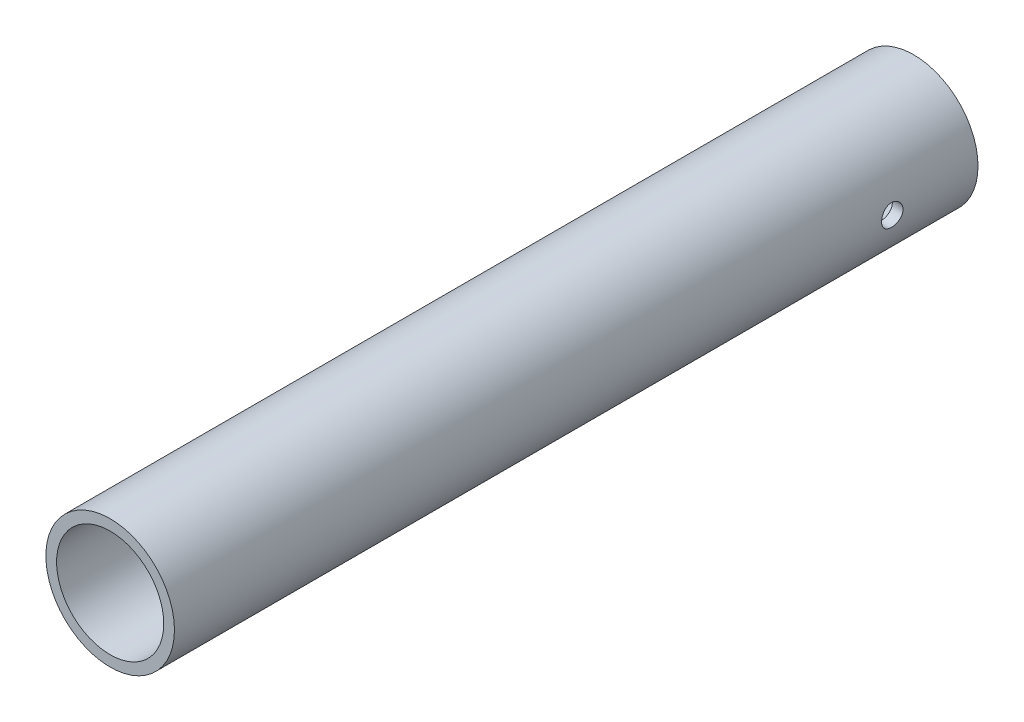
from build123d import *

# Parameters (mm, degrees)
SKETCH1_R                  = 6
SKETCH1_R_2                = 5
BOSS_EXTRUDE1_DEPTH        = 75
IZIM1_R                    = 1
KES_EKSTR_ZYON1_DEPTH      = 7
KES_EKSTR_ZYON1_DEPTH_BACK = 7


with BuildPart() as part:
    # Sketch1 → Boss-Extrude1 (new body)
    with BuildSketch(Plane.XY):
        Circle(SKETCH1_R)
        Circle(SKETCH1_R_2, mode=Mode.SUBTRACT)
    extrude(amount=BOSS_EXTRUDE1_DEPTH)

    # Çizim1 → Kes-Ekstrüzyon1 (cut, two sides)
    with BuildSketch(Plane(origin=(0, 0, 0), x_dir=(0, 0, -1), z_dir=(1, 0, 0))) as kes_ekstr_zyon1_sk:
        with Locations((-8, 0)):
            Circle(IZIM1_R)
    extrude(amount=KES_EKSTR_ZYON1_DEPTH, mode=Mode.SUBTRACT)
    extrude(kes_ekstr_zyon1_sk.sketch, amount=-KES_EKSTR_ZYON1_DEPTH_BACK, mode=Mode.SUBTRACT)


solid = part.part
